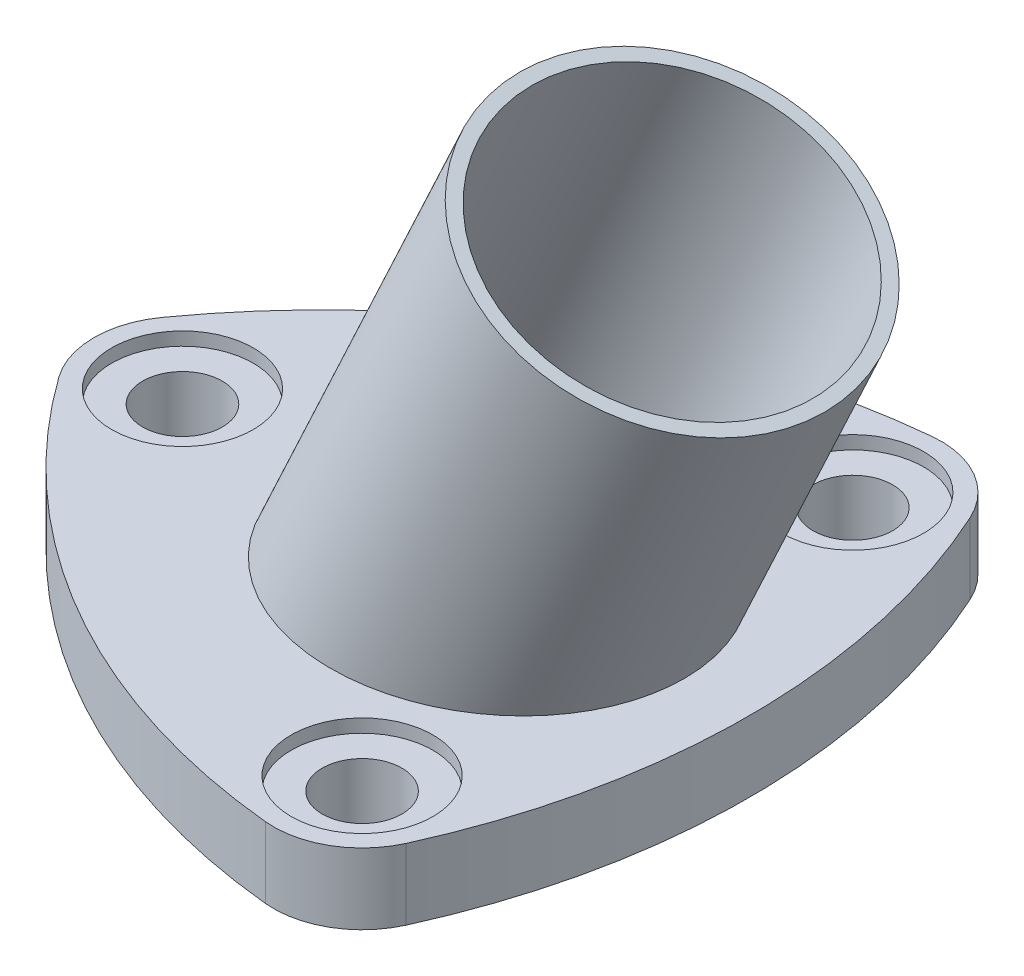
from build123d import *

# Parameters (mm, degrees)
SKETCH_1_R          = 4.5
EXTRUDE_1_DEPTH     = 8
SKETCH_5_R          = 8
CUT_EXTRUDE_2_DEPTH = 1.5
EXTRUDE_3_REACH     = 106.638
SKETCH_4_R          = 19
SKETCH_4_3_R        = 17.5
CUT_EXTRUDE_3_DEPTH = 91.489532559


with BuildPart() as part:
    # 草圖1 → 填料-伸長1 (new body)
    with BuildSketch(Plane(origin=(0, 0, 0), x_dir=(1, 0, 0), z_dir=(0, 1, 0))):
        with BuildLine():
            ThreePointArc((-40.134328358, -5.816588533), (-42, 0), (-40.134328358, 5.816588533))
            ThreePointArc((-40.134328358, 5.816588533), (-16, 27.712812921), (15.029850746, 37.665642188))
            ThreePointArc((15.029850746, 37.665642188), (21, 36.373066959), (25.104477612, 31.849053656))
            ThreePointArc((25.104477612, 31.849053656), (32, 0), (25.104477612, -31.849053656))
            ThreePointArc((25.104477612, -31.849053656), (21, -36.373066959), (15.029850746, -37.665642188))
            ThreePointArc((15.029850746, -37.665642188), (-16, -27.712812921), (-40.134328358, -5.816588533))
        make_face()
        with Locations((-32, 0)):
            Circle(SKETCH_1_R, mode=Mode.SUBTRACT)
        with Locations((16, 27.712812921)):
            Circle(SKETCH_1_R, mode=Mode.SUBTRACT)
        with Locations((16, -27.712812921)):
            Circle(SKETCH_1_R, mode=Mode.SUBTRACT)
    extrude(amount=EXTRUDE_1_DEPTH)

    # 草圖5 → 除料-伸長2 (cut)
    with BuildSketch(Plane(origin=(0, 8, 0), x_dir=(1, 0, 0), z_dir=(0, 1, 0))):
        with Locations((-32, 0)):
            Circle(SKETCH_5_R)
        with Locations((16, 27.712812921)):
            Circle(SKETCH_5_R)
        with Locations((16, -27.712812921)):
            Circle(SKETCH_5_R)
    extrude(amount=-CUT_EXTRUDE_2_DEPTH, mode=Mode.SUBTRACT)

    # 填料-伸長3: up to this plane
    extrude_3_end = Plane(origin=(19.25, 8, -5.629165125), z_dir=(0, 1, 0))
    # 草圖4 → 填料-伸長3 (add, up to the surface)
    with BuildSketch(Plane(origin=(23.315382908, 50, 0), x_dir=(0.906307787036651, -0.4226182617406974, 0), z_dir=(0.4226182617406974, 0.906307787036651, 0)), mode=Mode.PRIVATE) as extrude_3_sk1:
        Circle(SKETCH_4_R)
    extrude_3_tool1 = split(extrude(extrude_3_sk1.sketch, amount=-EXTRUDE_3_REACH, mode=Mode.PRIVATE), bisect_by=extrude_3_end, keep=Keep.BOTH, mode=Mode.PRIVATE)
    add(extrude_3_tool1.solids().sort_by_distance((23.315383, 50, 0))[0])

    # 草圖4<3> → 除料-伸長3 (cut, through all)
    with BuildSketch(Plane(origin=(23.315382908, 50, 0), x_dir=(0.906307787036651, -0.4226182617406974, 0), z_dir=(0.4226182617406974, 0.906307787036651, 0))):
        Circle(SKETCH_4_3_R)
    extrude(amount=-CUT_EXTRUDE_3_DEPTH, mode=Mode.SUBTRACT)


solid = part.part
